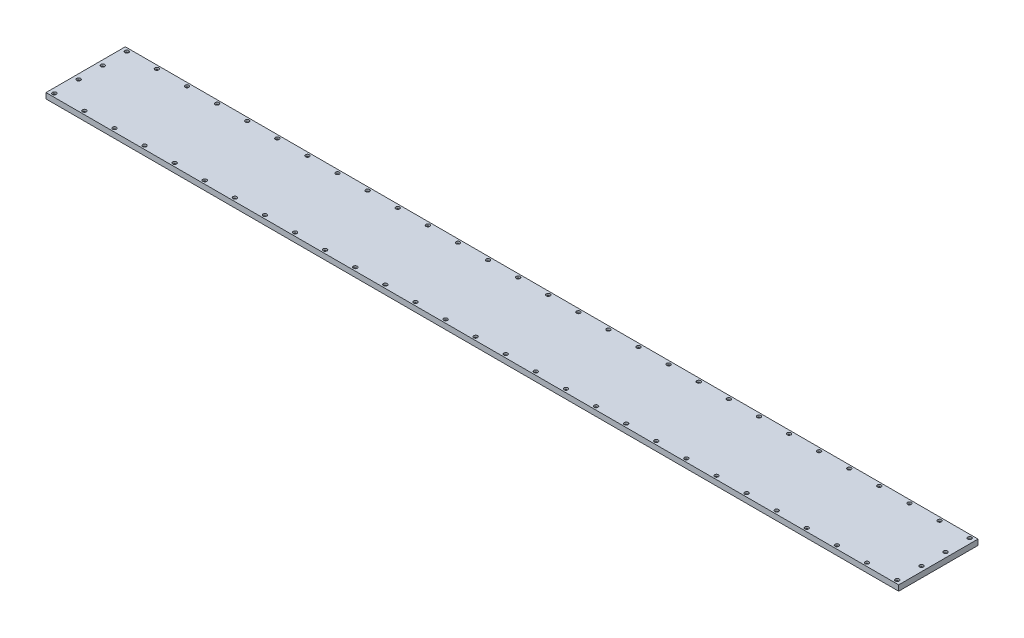
from build123d import *

# Parameters (mm, degrees)
SKETCH2_W                = 1075
SKETCH2_H                = 100
BOSS_EXTRUDE1_DEPTH      = 7
SKETCH3_R                = 1.7
CUT_EXTRUDE1_DEPTH       = 8
SKETCH4_R                = 2.4
CUT_EXTRUDE2_DEPTH       = 2.5
LPATTERN1_COUNT          = 4
LPATTERN1_PITCH          = 30.425
MIRROR1_COPY_1_SKETCH_R  = 1.7
MIRROR1_COPY_1_DEPTH     = 8
MIRROR1_COPY_2_SKETCH_R  = 1.7
MIRROR1_COPY_2_DEPTH     = 8
MIRROR1_COPY_3_SKETCH_R  = 1.7
MIRROR1_COPY_3_DEPTH     = 8
MIRROR1_COPY_4_SKETCH_R  = 2.4
MIRROR1_COPY_4_DEPTH     = 2.5
MIRROR1_COPY_5_SKETCH_R  = 2.4
MIRROR1_COPY_5_DEPTH     = 2.5
MIRROR1_COPY_6_SKETCH_R  = 2.4
MIRROR1_COPY_6_DEPTH     = 2.5
LPATTERN2_COUNT          = 29
LPATTERN2_PITCH          = 37.95
MIRROR2_COPY_1_SKETCH_R  = 1.7
MIRROR2_COPY_1_DEPTH     = 8
MIRROR2_COPY_2_SKETCH_R  = 1.7
MIRROR2_COPY_2_DEPTH     = 8
MIRROR2_COPY_3_SKETCH_R  = 1.7
MIRROR2_COPY_3_DEPTH     = 8
MIRROR2_COPY_4_SKETCH_R  = 1.7
MIRROR2_COPY_4_DEPTH     = 8
MIRROR2_COPY_5_SKETCH_R  = 1.7
MIRROR2_COPY_5_DEPTH     = 8
MIRROR2_COPY_6_SKETCH_R  = 1.7
MIRROR2_COPY_6_DEPTH     = 8
MIRROR2_COPY_7_SKETCH_R  = 1.7
MIRROR2_COPY_7_DEPTH     = 8
MIRROR2_COPY_8_SKETCH_R  = 1.7
MIRROR2_COPY_8_DEPTH     = 8
MIRROR2_COPY_9_SKETCH_R  = 1.7
MIRROR2_COPY_9_DEPTH     = 8
MIRROR2_COPY_10_SKETCH_R = 1.7
MIRROR2_COPY_10_DEPTH    = 8
MIRROR2_COPY_11_SKETCH_R = 1.7
MIRROR2_COPY_11_DEPTH    = 8
MIRROR2_COPY_12_SKETCH_R = 1.7
MIRROR2_COPY_12_DEPTH    = 8
MIRROR2_COPY_13_SKETCH_R = 1.7
MIRROR2_COPY_13_DEPTH    = 8
MIRROR2_COPY_14_SKETCH_R = 1.7
MIRROR2_COPY_14_DEPTH    = 8
MIRROR2_COPY_15_SKETCH_R = 1.7
MIRROR2_COPY_15_DEPTH    = 8
MIRROR2_COPY_16_SKETCH_R = 1.7
MIRROR2_COPY_16_DEPTH    = 8
MIRROR2_COPY_17_SKETCH_R = 1.7
MIRROR2_COPY_17_DEPTH    = 8
MIRROR2_COPY_18_SKETCH_R = 1.7
MIRROR2_COPY_18_DEPTH    = 8
MIRROR2_COPY_19_SKETCH_R = 1.7
MIRROR2_COPY_19_DEPTH    = 8
MIRROR2_COPY_20_SKETCH_R = 1.7
MIRROR2_COPY_20_DEPTH    = 8
MIRROR2_COPY_21_SKETCH_R = 1.7
MIRROR2_COPY_21_DEPTH    = 8
MIRROR2_COPY_22_SKETCH_R = 1.7
MIRROR2_COPY_22_DEPTH    = 8
MIRROR2_COPY_23_SKETCH_R = 1.7
MIRROR2_COPY_23_DEPTH    = 8
MIRROR2_COPY_24_SKETCH_R = 1.7
MIRROR2_COPY_24_DEPTH    = 8
MIRROR2_COPY_25_SKETCH_R = 1.7
MIRROR2_COPY_25_DEPTH    = 8
MIRROR2_COPY_26_SKETCH_R = 1.7
MIRROR2_COPY_26_DEPTH    = 8
MIRROR2_COPY_27_SKETCH_R = 1.7
MIRROR2_COPY_27_DEPTH    = 8
MIRROR2_COPY_28_SKETCH_R = 1.7
MIRROR2_COPY_28_DEPTH    = 8
MIRROR2_COPY_29_SKETCH_R = 2.4
MIRROR2_COPY_29_DEPTH    = 2.5
MIRROR2_COPY_30_SKETCH_R = 2.4
MIRROR2_COPY_30_DEPTH    = 2.5
MIRROR2_COPY_31_SKETCH_R = 2.4
MIRROR2_COPY_31_DEPTH    = 2.5
MIRROR2_COPY_32_SKETCH_R = 2.4
MIRROR2_COPY_32_DEPTH    = 2.5
MIRROR2_COPY_33_SKETCH_R = 2.4
MIRROR2_COPY_33_DEPTH    = 2.5
MIRROR2_COPY_34_SKETCH_R = 2.4
MIRROR2_COPY_34_DEPTH    = 2.5
MIRROR2_COPY_35_SKETCH_R = 2.4
MIRROR2_COPY_35_DEPTH    = 2.5
MIRROR2_COPY_36_SKETCH_R = 2.4
MIRROR2_COPY_36_DEPTH    = 2.5
MIRROR2_COPY_37_SKETCH_R = 2.4
MIRROR2_COPY_37_DEPTH    = 2.5
MIRROR2_COPY_38_SKETCH_R = 2.4
MIRROR2_COPY_38_DEPTH    = 2.5
MIRROR2_COPY_39_SKETCH_R = 2.4
MIRROR2_COPY_39_DEPTH    = 2.5
MIRROR2_COPY_40_SKETCH_R = 2.4
MIRROR2_COPY_40_DEPTH    = 2.5
MIRROR2_COPY_41_SKETCH_R = 2.4
MIRROR2_COPY_41_DEPTH    = 2.5
MIRROR2_COPY_42_SKETCH_R = 2.4
MIRROR2_COPY_42_DEPTH    = 2.5
MIRROR2_COPY_43_SKETCH_R = 2.4
MIRROR2_COPY_43_DEPTH    = 2.5
MIRROR2_COPY_44_SKETCH_R = 2.4
MIRROR2_COPY_44_DEPTH    = 2.5
MIRROR2_COPY_45_SKETCH_R = 2.4
MIRROR2_COPY_45_DEPTH    = 2.5
MIRROR2_COPY_46_SKETCH_R = 2.4
MIRROR2_COPY_46_DEPTH    = 2.5
MIRROR2_COPY_47_SKETCH_R = 2.4
MIRROR2_COPY_47_DEPTH    = 2.5
MIRROR2_COPY_48_SKETCH_R = 2.4
MIRROR2_COPY_48_DEPTH    = 2.5
MIRROR2_COPY_49_SKETCH_R = 2.4
MIRROR2_COPY_49_DEPTH    = 2.5
MIRROR2_COPY_50_SKETCH_R = 2.4
MIRROR2_COPY_50_DEPTH    = 2.5
MIRROR2_COPY_51_SKETCH_R = 2.4
MIRROR2_COPY_51_DEPTH    = 2.5
MIRROR2_COPY_52_SKETCH_R = 2.4
MIRROR2_COPY_52_DEPTH    = 2.5
MIRROR2_COPY_53_SKETCH_R = 2.4
MIRROR2_COPY_53_DEPTH    = 2.5
MIRROR2_COPY_54_SKETCH_R = 2.4
MIRROR2_COPY_54_DEPTH    = 2.5
MIRROR2_COPY_55_SKETCH_R = 2.4
MIRROR2_COPY_55_DEPTH    = 2.5
MIRROR2_COPY_56_SKETCH_R = 2.4
MIRROR2_COPY_56_DEPTH    = 2.5


with BuildPart() as part:
    # Sketch2 → Boss-Extrude1 (new body)
    with BuildSketch(Plane(origin=(0, 0, 0), x_dir=(1, 0, 0), z_dir=(0, 1, 0))):
        Rectangle(SKETCH2_W, SKETCH2_H)
    extrude(amount=BOSS_EXTRUDE1_DEPTH)

    # Sketch3 → Cut-Extrude1 (cut, through all)
    with BuildSketch(Plane(origin=(0, 7, 0), x_dir=(1, 0, 0), z_dir=(0, 1, 0))):
        with Locations((531.25, 45.75)):
            Circle(SKETCH3_R)
    cut_extrude1 = extrude(amount=-CUT_EXTRUDE1_DEPTH, mode=Mode.SUBTRACT)

    # Sketch4 → Cut-Extrude2 (cut)
    with BuildSketch(Plane(origin=(0, 7, 0), x_dir=(1, 0, 0), z_dir=(0, 1, 0))):
        with Locations((531.25, 45.75)):
            Circle(SKETCH4_R)
    cut_extrude2 = extrude(amount=-CUT_EXTRUDE2_DEPTH, mode=Mode.SUBTRACT)

    # LPattern1: Cut-Extrude1, Cut-Extrude2 ×4
    with Locations(*[(0, 0, i * LPATTERN1_PITCH) for i in range(1, LPATTERN1_COUNT)]):
        add(cut_extrude1, mode=Mode.SUBTRACT)
        add(cut_extrude2, mode=Mode.SUBTRACT)

    # Mirror1: Cut-Extrude1, Cut-Extrude2 across plane
    add(cut_extrude1.mirror(Plane(origin=(0, 0, 0), x_dir=(0, 0, 1), z_dir=(1, 0, 0))), mode=Mode.SUBTRACT)
    add(cut_extrude2.mirror(Plane(origin=(0, 0, 0), x_dir=(0, 0, 1), z_dir=(1, 0, 0))), mode=Mode.SUBTRACT)

    # Mirror1 copy 1 sketch → Mirror1 copy 1 (cut, through all)
    with BuildSketch(Plane(origin=(0, 7, 30.425), x_dir=(-1, 0, 0), z_dir=(0, 1, 0))):
        with Locations((531.25, -45.75)):
            Circle(MIRROR1_COPY_1_SKETCH_R)
    extrude(amount=-MIRROR1_COPY_1_DEPTH, mode=Mode.SUBTRACT)

    # Mirror1 copy 2 sketch → Mirror1 copy 2 (cut, through all)
    with BuildSketch(Plane(origin=(0, 7, 60.85), x_dir=(-1, 0, 0), z_dir=(0, 1, 0))):
        with Locations((531.25, -45.75)):
            Circle(MIRROR1_COPY_2_SKETCH_R)
    extrude(amount=-MIRROR1_COPY_2_DEPTH, mode=Mode.SUBTRACT)

    # Mirror1 copy 3 sketch → Mirror1 copy 3 (cut, through all)
    with BuildSketch(Plane(origin=(0, 7, 91.275), x_dir=(-1, 0, 0), z_dir=(0, 1, 0))):
        with Locations((531.25, -45.75)):
            Circle(MIRROR1_COPY_3_SKETCH_R)
    extrude(amount=-MIRROR1_COPY_3_DEPTH, mode=Mode.SUBTRACT)

    # Mirror1 copy 4 sketch → Mirror1 copy 4 (cut)
    with BuildSketch(Plane(origin=(0, 7, 30.425), x_dir=(-1, 0, 0), z_dir=(0, 1, 0))):
        with Locations((531.25, -45.75)):
            Circle(MIRROR1_COPY_4_SKETCH_R)
    extrude(amount=-MIRROR1_COPY_4_DEPTH, mode=Mode.SUBTRACT)

    # Mirror1 copy 5 sketch → Mirror1 copy 5 (cut)
    with BuildSketch(Plane(origin=(0, 7, 60.85), x_dir=(-1, 0, 0), z_dir=(0, 1, 0))):
        with Locations((531.25, -45.75)):
            Circle(MIRROR1_COPY_5_SKETCH_R)
    extrude(amount=-MIRROR1_COPY_5_DEPTH, mode=Mode.SUBTRACT)

    # Mirror1 copy 6 sketch → Mirror1 copy 6 (cut)
    with BuildSketch(Plane(origin=(0, 7, 91.275), x_dir=(-1, 0, 0), z_dir=(0, 1, 0))):
        with Locations((531.25, -45.75)):
            Circle(MIRROR1_COPY_6_SKETCH_R)
    extrude(amount=-MIRROR1_COPY_6_DEPTH, mode=Mode.SUBTRACT)

    # LPattern2: Cut-Extrude1, Cut-Extrude2 ×29
    with Locations(*[(-i * LPATTERN2_PITCH, 0, 0) for i in range(1, LPATTERN2_COUNT)]):
        add(cut_extrude1, mode=Mode.SUBTRACT)
        add(cut_extrude2, mode=Mode.SUBTRACT)

    # Mirror2: Cut-Extrude1, Cut-Extrude2 across plane
    add(cut_extrude1.mirror(Plane(origin=(0, 0, 0), x_dir=(1, 0, 0), z_dir=(0, 0, -1))), mode=Mode.SUBTRACT)
    add(cut_extrude2.mirror(Plane(origin=(0, 0, 0), x_dir=(1, 0, 0), z_dir=(0, 0, -1))), mode=Mode.SUBTRACT)

    # Mirror2 copy 1 sketch → Mirror2 copy 1 (cut, through all)
    with BuildSketch(Plane(origin=(-37.95, 7, 0), x_dir=(1, 0, 0), z_dir=(0, 1, 0))):
        with Locations((531.25, -45.75)):
            Circle(MIRROR2_COPY_1_SKETCH_R)
    extrude(amount=-MIRROR2_COPY_1_DEPTH, mode=Mode.SUBTRACT)

    # Mirror2 copy 2 sketch → Mirror2 copy 2 (cut, through all)
    with BuildSketch(Plane(origin=(-75.9, 7, 0), x_dir=(1, 0, 0), z_dir=(0, 1, 0))):
        with Locations((531.25, -45.75)):
            Circle(MIRROR2_COPY_2_SKETCH_R)
    extrude(amount=-MIRROR2_COPY_2_DEPTH, mode=Mode.SUBTRACT)

    # Mirror2 copy 3 sketch → Mirror2 copy 3 (cut, through all)
    with BuildSketch(Plane(origin=(-113.85, 7, 0), x_dir=(1, 0, 0), z_dir=(0, 1, 0))):
        with Locations((531.25, -45.75)):
            Circle(MIRROR2_COPY_3_SKETCH_R)
    extrude(amount=-MIRROR2_COPY_3_DEPTH, mode=Mode.SUBTRACT)

    # Mirror2 copy 4 sketch → Mirror2 copy 4 (cut, through all)
    with BuildSketch(Plane(origin=(-151.8, 7, 0), x_dir=(1, 0, 0), z_dir=(0, 1, 0))):
        with Locations((531.25, -45.75)):
            Circle(MIRROR2_COPY_4_SKETCH_R)
    extrude(amount=-MIRROR2_COPY_4_DEPTH, mode=Mode.SUBTRACT)

    # Mirror2 copy 5 sketch → Mirror2 copy 5 (cut, through all)
    with BuildSketch(Plane(origin=(-189.75, 7, 0), x_dir=(1, 0, 0), z_dir=(0, 1, 0))):
        with Locations((531.25, -45.75)):
            Circle(MIRROR2_COPY_5_SKETCH_R)
    extrude(amount=-MIRROR2_COPY_5_DEPTH, mode=Mode.SUBTRACT)

    # Mirror2 copy 6 sketch → Mirror2 copy 6 (cut, through all)
    with BuildSketch(Plane(origin=(-227.7, 7, 0), x_dir=(1, 0, 0), z_dir=(0, 1, 0))):
        with Locations((531.25, -45.75)):
            Circle(MIRROR2_COPY_6_SKETCH_R)
    extrude(amount=-MIRROR2_COPY_6_DEPTH, mode=Mode.SUBTRACT)

    # Mirror2 copy 7 sketch → Mirror2 copy 7 (cut, through all)
    with BuildSketch(Plane(origin=(-265.65, 7, 0), x_dir=(1, 0, 0), z_dir=(0, 1, 0))):
        with Locations((531.25, -45.75)):
            Circle(MIRROR2_COPY_7_SKETCH_R)
    extrude(amount=-MIRROR2_COPY_7_DEPTH, mode=Mode.SUBTRACT)

    # Mirror2 copy 8 sketch → Mirror2 copy 8 (cut, through all)
    with BuildSketch(Plane(origin=(-303.6, 7, 0), x_dir=(1, 0, 0), z_dir=(0, 1, 0))):
        with Locations((531.25, -45.75)):
            Circle(MIRROR2_COPY_8_SKETCH_R)
    extrude(amount=-MIRROR2_COPY_8_DEPTH, mode=Mode.SUBTRACT)

    # Mirror2 copy 9 sketch → Mirror2 copy 9 (cut, through all)
    with BuildSketch(Plane(origin=(-341.55, 7, 0), x_dir=(1, 0, 0), z_dir=(0, 1, 0))):
        with Locations((531.25, -45.75)):
            Circle(MIRROR2_COPY_9_SKETCH_R)
    extrude(amount=-MIRROR2_COPY_9_DEPTH, mode=Mode.SUBTRACT)

    # Mirror2 copy 10 sketch → Mirror2 copy 10 (cut, through all)
    with BuildSketch(Plane(origin=(-379.5, 7, 0), x_dir=(1, 0, 0), z_dir=(0, 1, 0))):
        with Locations((531.25, -45.75)):
            Circle(MIRROR2_COPY_10_SKETCH_R)
    extrude(amount=-MIRROR2_COPY_10_DEPTH, mode=Mode.SUBTRACT)

    # Mirror2 copy 11 sketch → Mirror2 copy 11 (cut, through all)
    with BuildSketch(Plane(origin=(-417.45, 7, 0), x_dir=(1, 0, 0), z_dir=(0, 1, 0))):
        with Locations((531.25, -45.75)):
            Circle(MIRROR2_COPY_11_SKETCH_R)
    extrude(amount=-MIRROR2_COPY_11_DEPTH, mode=Mode.SUBTRACT)

    # Mirror2 copy 12 sketch → Mirror2 copy 12 (cut, through all)
    with BuildSketch(Plane(origin=(-455.4, 7, 0), x_dir=(1, 0, 0), z_dir=(0, 1, 0))):
        with Locations((531.25, -45.75)):
            Circle(MIRROR2_COPY_12_SKETCH_R)
    extrude(amount=-MIRROR2_COPY_12_DEPTH, mode=Mode.SUBTRACT)

    # Mirror2 copy 13 sketch → Mirror2 copy 13 (cut, through all)
    with BuildSketch(Plane(origin=(-493.35, 7, 0), x_dir=(1, 0, 0), z_dir=(0, 1, 0))):
        with Locations((531.25, -45.75)):
            Circle(MIRROR2_COPY_13_SKETCH_R)
    extrude(amount=-MIRROR2_COPY_13_DEPTH, mode=Mode.SUBTRACT)

    # Mirror2 copy 14 sketch → Mirror2 copy 14 (cut, through all)
    with BuildSketch(Plane(origin=(-531.3, 7, 0), x_dir=(1, 0, 0), z_dir=(0, 1, 0))):
        with Locations((531.25, -45.75)):
            Circle(MIRROR2_COPY_14_SKETCH_R)
    extrude(amount=-MIRROR2_COPY_14_DEPTH, mode=Mode.SUBTRACT)

    # Mirror2 copy 15 sketch → Mirror2 copy 15 (cut, through all)
    with BuildSketch(Plane(origin=(-569.25, 7, 0), x_dir=(1, 0, 0), z_dir=(0, 1, 0))):
        with Locations((531.25, -45.75)):
            Circle(MIRROR2_COPY_15_SKETCH_R)
    extrude(amount=-MIRROR2_COPY_15_DEPTH, mode=Mode.SUBTRACT)

    # Mirror2 copy 16 sketch → Mirror2 copy 16 (cut, through all)
    with BuildSketch(Plane(origin=(-607.2, 7, 0), x_dir=(1, 0, 0), z_dir=(0, 1, 0))):
        with Locations((531.25, -45.75)):
            Circle(MIRROR2_COPY_16_SKETCH_R)
    extrude(amount=-MIRROR2_COPY_16_DEPTH, mode=Mode.SUBTRACT)

    # Mirror2 copy 17 sketch → Mirror2 copy 17 (cut, through all)
    with BuildSketch(Plane(origin=(-645.15, 7, 0), x_dir=(1, 0, 0), z_dir=(0, 1, 0))):
        with Locations((531.25, -45.75)):
            Circle(MIRROR2_COPY_17_SKETCH_R)
    extrude(amount=-MIRROR2_COPY_17_DEPTH, mode=Mode.SUBTRACT)

    # Mirror2 copy 18 sketch → Mirror2 copy 18 (cut, through all)
    with BuildSketch(Plane(origin=(-683.1, 7, 0), x_dir=(1, 0, 0), z_dir=(0, 1, 0))):
        with Locations((531.25, -45.75)):
            Circle(MIRROR2_COPY_18_SKETCH_R)
    extrude(amount=-MIRROR2_COPY_18_DEPTH, mode=Mode.SUBTRACT)

    # Mirror2 copy 19 sketch → Mirror2 copy 19 (cut, through all)
    with BuildSketch(Plane(origin=(-721.05, 7, 0), x_dir=(1, 0, 0), z_dir=(0, 1, 0))):
        with Locations((531.25, -45.75)):
            Circle(MIRROR2_COPY_19_SKETCH_R)
    extrude(amount=-MIRROR2_COPY_19_DEPTH, mode=Mode.SUBTRACT)

    # Mirror2 copy 20 sketch → Mirror2 copy 20 (cut, through all)
    with BuildSketch(Plane(origin=(-759, 7, 0), x_dir=(1, 0, 0), z_dir=(0, 1, 0))):
        with Locations((531.25, -45.75)):
            Circle(MIRROR2_COPY_20_SKETCH_R)
    extrude(amount=-MIRROR2_COPY_20_DEPTH, mode=Mode.SUBTRACT)

    # Mirror2 copy 21 sketch → Mirror2 copy 21 (cut, through all)
    with BuildSketch(Plane(origin=(-796.95, 7, 0), x_dir=(1, 0, 0), z_dir=(0, 1, 0))):
        with Locations((531.25, -45.75)):
            Circle(MIRROR2_COPY_21_SKETCH_R)
    extrude(amount=-MIRROR2_COPY_21_DEPTH, mode=Mode.SUBTRACT)

    # Mirror2 copy 22 sketch → Mirror2 copy 22 (cut, through all)
    with BuildSketch(Plane(origin=(-834.9, 7, 0), x_dir=(1, 0, 0), z_dir=(0, 1, 0))):
        with Locations((531.25, -45.75)):
            Circle(MIRROR2_COPY_22_SKETCH_R)
    extrude(amount=-MIRROR2_COPY_22_DEPTH, mode=Mode.SUBTRACT)

    # Mirror2 copy 23 sketch → Mirror2 copy 23 (cut, through all)
    with BuildSketch(Plane(origin=(-872.85, 7, 0), x_dir=(1, 0, 0), z_dir=(0, 1, 0))):
        with Locations((531.25, -45.75)):
            Circle(MIRROR2_COPY_23_SKETCH_R)
    extrude(amount=-MIRROR2_COPY_23_DEPTH, mode=Mode.SUBTRACT)

    # Mirror2 copy 24 sketch → Mirror2 copy 24 (cut, through all)
    with BuildSketch(Plane(origin=(-910.8, 7, 0), x_dir=(1, 0, 0), z_dir=(0, 1, 0))):
        with Locations((531.25, -45.75)):
            Circle(MIRROR2_COPY_24_SKETCH_R)
    extrude(amount=-MIRROR2_COPY_24_DEPTH, mode=Mode.SUBTRACT)

    # Mirror2 copy 25 sketch → Mirror2 copy 25 (cut, through all)
    with BuildSketch(Plane(origin=(-948.75, 7, 0), x_dir=(1, 0, 0), z_dir=(0, 1, 0))):
        with Locations((531.25, -45.75)):
            Circle(MIRROR2_COPY_25_SKETCH_R)
    extrude(amount=-MIRROR2_COPY_25_DEPTH, mode=Mode.SUBTRACT)

    # Mirror2 copy 26 sketch → Mirror2 copy 26 (cut, through all)
    with BuildSketch(Plane(origin=(-986.7, 7, 0), x_dir=(1, 0, 0), z_dir=(0, 1, 0))):
        with Locations((531.25, -45.75)):
            Circle(MIRROR2_COPY_26_SKETCH_R)
    extrude(amount=-MIRROR2_COPY_26_DEPTH, mode=Mode.SUBTRACT)

    # Mirror2 copy 27 sketch → Mirror2 copy 27 (cut, through all)
    with BuildSketch(Plane(origin=(-1024.65, 7, 0), x_dir=(1, 0, 0), z_dir=(0, 1, 0))):
        with Locations((531.25, -45.75)):
            Circle(MIRROR2_COPY_27_SKETCH_R)
    extrude(amount=-MIRROR2_COPY_27_DEPTH, mode=Mode.SUBTRACT)

    # Mirror2 copy 28 sketch → Mirror2 copy 28 (cut, through all)
    with BuildSketch(Plane(origin=(-1062.6, 7, 0), x_dir=(1, 0, 0), z_dir=(0, 1, 0))):
        with Locations((531.25, -45.75)):
            Circle(MIRROR2_COPY_28_SKETCH_R)
    extrude(amount=-MIRROR2_COPY_28_DEPTH, mode=Mode.SUBTRACT)

    # Mirror2 copy 29 sketch → Mirror2 copy 29 (cut)
    with BuildSketch(Plane(origin=(-37.95, 7, 0), x_dir=(1, 0, 0), z_dir=(0, 1, 0))):
        with Locations((531.25, -45.75)):
            Circle(MIRROR2_COPY_29_SKETCH_R)
    extrude(amount=-MIRROR2_COPY_29_DEPTH, mode=Mode.SUBTRACT)

    # Mirror2 copy 30 sketch → Mirror2 copy 30 (cut)
    with BuildSketch(Plane(origin=(-75.9, 7, 0), x_dir=(1, 0, 0), z_dir=(0, 1, 0))):
        with Locations((531.25, -45.75)):
            Circle(MIRROR2_COPY_30_SKETCH_R)
    extrude(amount=-MIRROR2_COPY_30_DEPTH, mode=Mode.SUBTRACT)

    # Mirror2 copy 31 sketch → Mirror2 copy 31 (cut)
    with BuildSketch(Plane(origin=(-113.85, 7, 0), x_dir=(1, 0, 0), z_dir=(0, 1, 0))):
        with Locations((531.25, -45.75)):
            Circle(MIRROR2_COPY_31_SKETCH_R)
    extrude(amount=-MIRROR2_COPY_31_DEPTH, mode=Mode.SUBTRACT)

    # Mirror2 copy 32 sketch → Mirror2 copy 32 (cut)
    with BuildSketch(Plane(origin=(-151.8, 7, 0), x_dir=(1, 0, 0), z_dir=(0, 1, 0))):
        with Locations((531.25, -45.75)):
            Circle(MIRROR2_COPY_32_SKETCH_R)
    extrude(amount=-MIRROR2_COPY_32_DEPTH, mode=Mode.SUBTRACT)

    # Mirror2 copy 33 sketch → Mirror2 copy 33 (cut)
    with BuildSketch(Plane(origin=(-189.75, 7, 0), x_dir=(1, 0, 0), z_dir=(0, 1, 0))):
        with Locations((531.25, -45.75)):
            Circle(MIRROR2_COPY_33_SKETCH_R)
    extrude(amount=-MIRROR2_COPY_33_DEPTH, mode=Mode.SUBTRACT)

    # Mirror2 copy 34 sketch → Mirror2 copy 34 (cut)
    with BuildSketch(Plane(origin=(-227.7, 7, 0), x_dir=(1, 0, 0), z_dir=(0, 1, 0))):
        with Locations((531.25, -45.75)):
            Circle(MIRROR2_COPY_34_SKETCH_R)
    extrude(amount=-MIRROR2_COPY_34_DEPTH, mode=Mode.SUBTRACT)

    # Mirror2 copy 35 sketch → Mirror2 copy 35 (cut)
    with BuildSketch(Plane(origin=(-265.65, 7, 0), x_dir=(1, 0, 0), z_dir=(0, 1, 0))):
        with Locations((531.25, -45.75)):
            Circle(MIRROR2_COPY_35_SKETCH_R)
    extrude(amount=-MIRROR2_COPY_35_DEPTH, mode=Mode.SUBTRACT)

    # Mirror2 copy 36 sketch → Mirror2 copy 36 (cut)
    with BuildSketch(Plane(origin=(-303.6, 7, 0), x_dir=(1, 0, 0), z_dir=(0, 1, 0))):
        with Locations((531.25, -45.75)):
            Circle(MIRROR2_COPY_36_SKETCH_R)
    extrude(amount=-MIRROR2_COPY_36_DEPTH, mode=Mode.SUBTRACT)

    # Mirror2 copy 37 sketch → Mirror2 copy 37 (cut)
    with BuildSketch(Plane(origin=(-341.55, 7, 0), x_dir=(1, 0, 0), z_dir=(0, 1, 0))):
        with Locations((531.25, -45.75)):
            Circle(MIRROR2_COPY_37_SKETCH_R)
    extrude(amount=-MIRROR2_COPY_37_DEPTH, mode=Mode.SUBTRACT)

    # Mirror2 copy 38 sketch → Mirror2 copy 38 (cut)
    with BuildSketch(Plane(origin=(-379.5, 7, 0), x_dir=(1, 0, 0), z_dir=(0, 1, 0))):
        with Locations((531.25, -45.75)):
            Circle(MIRROR2_COPY_38_SKETCH_R)
    extrude(amount=-MIRROR2_COPY_38_DEPTH, mode=Mode.SUBTRACT)

    # Mirror2 copy 39 sketch → Mirror2 copy 39 (cut)
    with BuildSketch(Plane(origin=(-417.45, 7, 0), x_dir=(1, 0, 0), z_dir=(0, 1, 0))):
        with Locations((531.25, -45.75)):
            Circle(MIRROR2_COPY_39_SKETCH_R)
    extrude(amount=-MIRROR2_COPY_39_DEPTH, mode=Mode.SUBTRACT)

    # Mirror2 copy 40 sketch → Mirror2 copy 40 (cut)
    with BuildSketch(Plane(origin=(-455.4, 7, 0), x_dir=(1, 0, 0), z_dir=(0, 1, 0))):
        with Locations((531.25, -45.75)):
            Circle(MIRROR2_COPY_40_SKETCH_R)
    extrude(amount=-MIRROR2_COPY_40_DEPTH, mode=Mode.SUBTRACT)

    # Mirror2 copy 41 sketch → Mirror2 copy 41 (cut)
    with BuildSketch(Plane(origin=(-493.35, 7, 0), x_dir=(1, 0, 0), z_dir=(0, 1, 0))):
        with Locations((531.25, -45.75)):
            Circle(MIRROR2_COPY_41_SKETCH_R)
    extrude(amount=-MIRROR2_COPY_41_DEPTH, mode=Mode.SUBTRACT)

    # Mirror2 copy 42 sketch → Mirror2 copy 42 (cut)
    with BuildSketch(Plane(origin=(-531.3, 7, 0), x_dir=(1, 0, 0), z_dir=(0, 1, 0))):
        with Locations((531.25, -45.75)):
            Circle(MIRROR2_COPY_42_SKETCH_R)
    extrude(amount=-MIRROR2_COPY_42_DEPTH, mode=Mode.SUBTRACT)

    # Mirror2 copy 43 sketch → Mirror2 copy 43 (cut)
    with BuildSketch(Plane(origin=(-569.25, 7, 0), x_dir=(1, 0, 0), z_dir=(0, 1, 0))):
        with Locations((531.25, -45.75)):
            Circle(MIRROR2_COPY_43_SKETCH_R)
    extrude(amount=-MIRROR2_COPY_43_DEPTH, mode=Mode.SUBTRACT)

    # Mirror2 copy 44 sketch → Mirror2 copy 44 (cut)
    with BuildSketch(Plane(origin=(-607.2, 7, 0), x_dir=(1, 0, 0), z_dir=(0, 1, 0))):
        with Locations((531.25, -45.75)):
            Circle(MIRROR2_COPY_44_SKETCH_R)
    extrude(amount=-MIRROR2_COPY_44_DEPTH, mode=Mode.SUBTRACT)

    # Mirror2 copy 45 sketch → Mirror2 copy 45 (cut)
    with BuildSketch(Plane(origin=(-645.15, 7, 0), x_dir=(1, 0, 0), z_dir=(0, 1, 0))):
        with Locations((531.25, -45.75)):
            Circle(MIRROR2_COPY_45_SKETCH_R)
    extrude(amount=-MIRROR2_COPY_45_DEPTH, mode=Mode.SUBTRACT)

    # Mirror2 copy 46 sketch → Mirror2 copy 46 (cut)
    with BuildSketch(Plane(origin=(-683.1, 7, 0), x_dir=(1, 0, 0), z_dir=(0, 1, 0))):
        with Locations((531.25, -45.75)):
            Circle(MIRROR2_COPY_46_SKETCH_R)
    extrude(amount=-MIRROR2_COPY_46_DEPTH, mode=Mode.SUBTRACT)

    # Mirror2 copy 47 sketch → Mirror2 copy 47 (cut)
    with BuildSketch(Plane(origin=(-721.05, 7, 0), x_dir=(1, 0, 0), z_dir=(0, 1, 0))):
        with Locations((531.25, -45.75)):
            Circle(MIRROR2_COPY_47_SKETCH_R)
    extrude(amount=-MIRROR2_COPY_47_DEPTH, mode=Mode.SUBTRACT)

    # Mirror2 copy 48 sketch → Mirror2 copy 48 (cut)
    with BuildSketch(Plane(origin=(-759, 7, 0), x_dir=(1, 0, 0), z_dir=(0, 1, 0))):
        with Locations((531.25, -45.75)):
            Circle(MIRROR2_COPY_48_SKETCH_R)
    extrude(amount=-MIRROR2_COPY_48_DEPTH, mode=Mode.SUBTRACT)

    # Mirror2 copy 49 sketch → Mirror2 copy 49 (cut)
    with BuildSketch(Plane(origin=(-796.95, 7, 0), x_dir=(1, 0, 0), z_dir=(0, 1, 0))):
        with Locations((531.25, -45.75)):
            Circle(MIRROR2_COPY_49_SKETCH_R)
    extrude(amount=-MIRROR2_COPY_49_DEPTH, mode=Mode.SUBTRACT)

    # Mirror2 copy 50 sketch → Mirror2 copy 50 (cut)
    with BuildSketch(Plane(origin=(-834.9, 7, 0), x_dir=(1, 0, 0), z_dir=(0, 1, 0))):
        with Locations((531.25, -45.75)):
            Circle(MIRROR2_COPY_50_SKETCH_R)
    extrude(amount=-MIRROR2_COPY_50_DEPTH, mode=Mode.SUBTRACT)

    # Mirror2 copy 51 sketch → Mirror2 copy 51 (cut)
    with BuildSketch(Plane(origin=(-872.85, 7, 0), x_dir=(1, 0, 0), z_dir=(0, 1, 0))):
        with Locations((531.25, -45.75)):
            Circle(MIRROR2_COPY_51_SKETCH_R)
    extrude(amount=-MIRROR2_COPY_51_DEPTH, mode=Mode.SUBTRACT)

    # Mirror2 copy 52 sketch → Mirror2 copy 52 (cut)
    with BuildSketch(Plane(origin=(-910.8, 7, 0), x_dir=(1, 0, 0), z_dir=(0, 1, 0))):
        with Locations((531.25, -45.75)):
            Circle(MIRROR2_COPY_52_SKETCH_R)
    extrude(amount=-MIRROR2_COPY_52_DEPTH, mode=Mode.SUBTRACT)

    # Mirror2 copy 53 sketch → Mirror2 copy 53 (cut)
    with BuildSketch(Plane(origin=(-948.75, 7, 0), x_dir=(1, 0, 0), z_dir=(0, 1, 0))):
        with Locations((531.25, -45.75)):
            Circle(MIRROR2_COPY_53_SKETCH_R)
    extrude(amount=-MIRROR2_COPY_53_DEPTH, mode=Mode.SUBTRACT)

    # Mirror2 copy 54 sketch → Mirror2 copy 54 (cut)
    with BuildSketch(Plane(origin=(-986.7, 7, 0), x_dir=(1, 0, 0), z_dir=(0, 1, 0))):
        with Locations((531.25, -45.75)):
            Circle(MIRROR2_COPY_54_SKETCH_R)
    extrude(amount=-MIRROR2_COPY_54_DEPTH, mode=Mode.SUBTRACT)

    # Mirror2 copy 55 sketch → Mirror2 copy 55 (cut)
    with BuildSketch(Plane(origin=(-1024.65, 7, 0), x_dir=(1, 0, 0), z_dir=(0, 1, 0))):
        with Locations((531.25, -45.75)):
            Circle(MIRROR2_COPY_55_SKETCH_R)
    extrude(amount=-MIRROR2_COPY_55_DEPTH, mode=Mode.SUBTRACT)

    # Mirror2 copy 56 sketch → Mirror2 copy 56 (cut)
    with BuildSketch(Plane(origin=(-1062.6, 7, 0), x_dir=(1, 0, 0), z_dir=(0, 1, 0))):
        with Locations((531.25, -45.75)):
            Circle(MIRROR2_COPY_56_SKETCH_R)
    extrude(amount=-MIRROR2_COPY_56_DEPTH, mode=Mode.SUBTRACT)


solid = part.part
